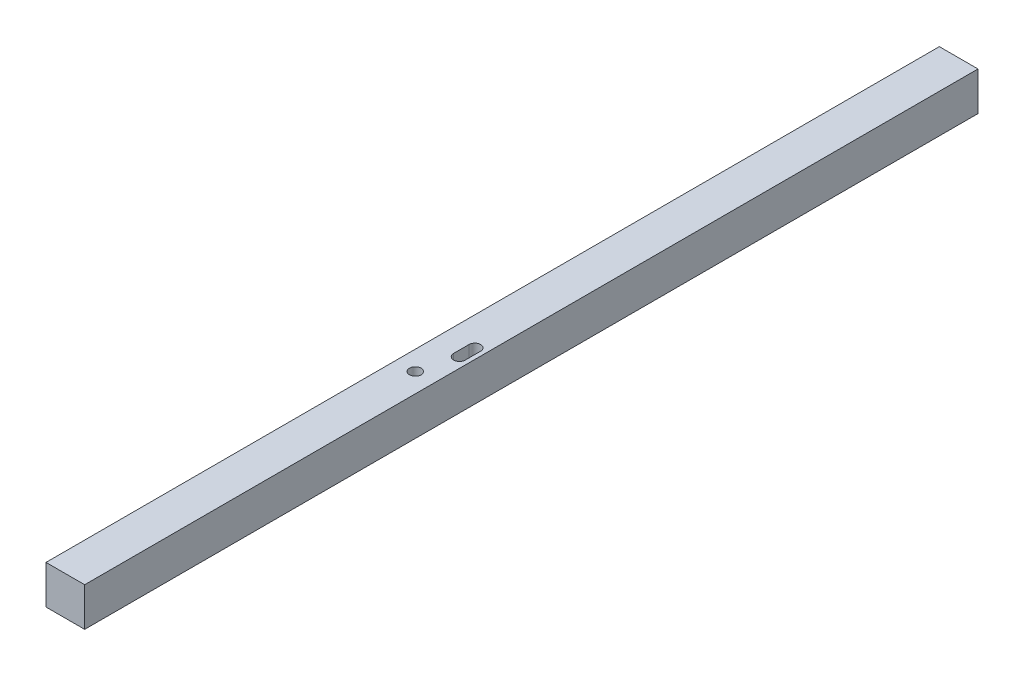
from build123d import *

# Parameters (mm, degrees)
ESQUISSE1_W             = 10
ESQUISSE1_H             = 10
BOSS_EXTRU_1_DEPTH      = 115.5
BOSS_EXTRU_1_DEPTH_BACK = 115.5
ESQUISSE2_R             = 1.5
ENL_V_MAT_EXTRU_1_DEPTH = 11
ENL_V_MAT_EXTRU_2_DEPTH = 11


with BuildPart() as part:
    # Esquisse1 → Boss.-Extru.1 (new body, two sides)
    with BuildSketch(Plane.XY) as boss_extru_1_sk:
        Rectangle(ESQUISSE1_W, ESQUISSE1_H)
    extrude(amount=BOSS_EXTRU_1_DEPTH)
    extrude(boss_extru_1_sk.sketch, amount=-BOSS_EXTRU_1_DEPTH_BACK)

    # Esquisse2 → Enlèv. mat.-Extru.1 (cut, through all)
    with BuildSketch(Plane.XZ.offset(5)):
        with Locations((0, 25)):
            Circle(ESQUISSE2_R)
    extrude(amount=-ENL_V_MAT_EXTRU_1_DEPTH, mode=Mode.SUBTRACT)

    # Esquisse3 → Enlèv. mat.-Extru.2 (cut, through all)
    with BuildSketch(Plane.XZ.offset(5)):
        with BuildLine():
            Line((0.9, 12), (0.9, 16))
            ThreePointArc((0.9, 16), (2.4, 17.5), (3.9, 16))
            Line((3.9, 16), (3.9, 12))
            ThreePointArc((3.9, 12), (2.4, 10.5), (0.9, 12))
        make_face()
    extrude(amount=-ENL_V_MAT_EXTRU_2_DEPTH, mode=Mode.SUBTRACT)


solid = part.part
